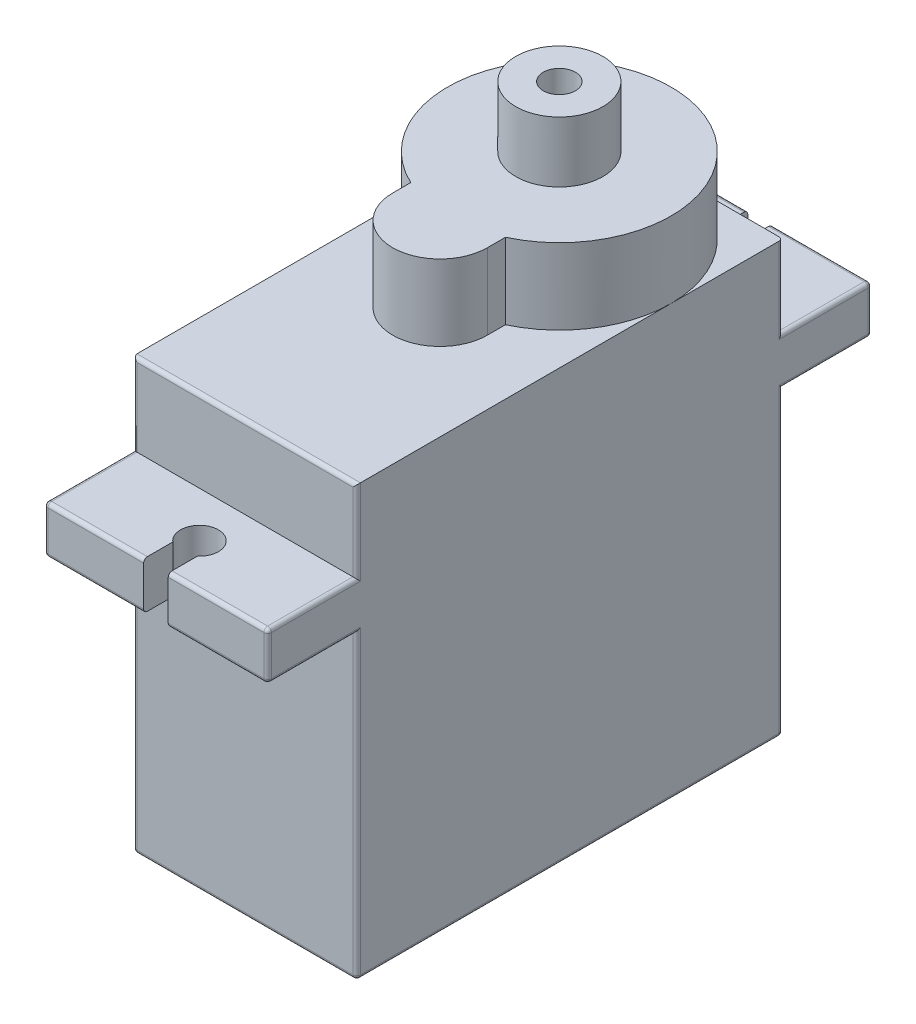
from build123d import *

# Parameters (mm, degrees)
ESQUISSE1_W        = 11.8
ESQUISSE1_H        = 22.5
BOSS_EXTRU_1_DEPTH = 15.9
BOSS_EXTRU_2_DEPTH = 2.5
ESQUISSE4_W        = 11.8
ESQUISSE4_H        = 22.5
BOSS_EXTRU_3_DEPTH = 4.3
BOSS_EXTRU_4_DEPTH = 4
ESQUISSE6_R        = 2.3
ESQUISSE6_R_2      = 0.85
BOSS_EXTRU_5_DEPTH = 3.2
CONG_1_R           = 0.2


with BuildPart() as part:
    # Esquisse1 → Boss.-Extru.1 (new body)
    with BuildSketch(Plane(origin=(0, 0, 0), x_dir=(1, 0, 0), z_dir=(0, 1, 0))):
        Rectangle(ESQUISSE1_W, ESQUISSE1_H)
    extrude(amount=BOSS_EXTRU_1_DEPTH)

    # Esquisse3 → Boss.-Extru.2 (add)
    with BuildSketch(Plane(origin=(0, 15.9, 0), x_dir=(1, 0, 0), z_dir=(0, 1, 0))):
        with BuildLine():
            Line((-5.9, 15.95), (-5.9, -15.95))
            Line((-5.9, -15.95), (-0.65, -15.95))
            Line((-0.65, -15.95), (-0.65, -14.409934208))
            ThreePointArc((-0.65, -14.409934208), (0, -12.65), (0.65, -14.409934208))
            Line((0.65, -14.409934208), (0.65, -15.95))
            Line((0.65, -15.95), (5.9, -15.95))
            Line((5.9, -15.95), (5.9, 15.95))
            Line((5.9, 15.95), (0.65, 15.95))
            Line((0.65, 15.95), (0.65, 14.409934208))
            ThreePointArc((0.65, 14.409934208), (0, 12.65), (-0.65, 14.409934208))
            Line((-0.65, 14.409934208), (-0.65, 15.95))
            Line((-0.65, 15.95), (-5.9, 15.95))
        make_face()
    extrude(amount=BOSS_EXTRU_2_DEPTH)

    # Esquisse4 → Boss.-Extru.3 (add)
    with BuildSketch(Plane(origin=(0, 18.4, 0), x_dir=(1, 0, 0), z_dir=(0, 1, 0))):
        Rectangle(ESQUISSE4_W, ESQUISSE4_H)
    extrude(amount=BOSS_EXTRU_3_DEPTH)

    # Esquisse5 → Boss.-Extru.4 (add)
    with BuildSketch(Plane(origin=(0, 22.7, 0), x_dir=(1, 0, 0), z_dir=(0, 1, 0))):
        with BuildLine():
            Line((2.5, -0.95), (2.5, 0.005844314))
            ThreePointArc((2.5, 0.005844314), (0, 11.25), (-2.5, 0.005844314))
            Line((-2.5, 0.005844314), (-2.5, -0.95))
            ThreePointArc((-2.5, -0.95), (0, -3.45), (2.5, -0.95))
        make_face()
    extrude(amount=BOSS_EXTRU_4_DEPTH)

    # Esquisse6 → Boss.-Extru.5 (add)
    with BuildSketch(Plane(origin=(0, 26.7, 0), x_dir=(1, 0, 0), z_dir=(0, 1, 0))):
        with Locations((0, 5.35)):
            Circle(ESQUISSE6_R)
        with Locations((0, 5.35)):
            Circle(ESQUISSE6_R_2, mode=Mode.SUBTRACT)
    extrude(amount=BOSS_EXTRU_5_DEPTH)

    # Congé1
    cong_1_edges = [part.edges().sort_by_distance(p)[0] for p in [
        (0, 0, -11.25),
        (-5.9, 17.15, -15.95),
        (5.9, 17.15, -15.95),
        (5.9, 15.9, -13.6),
        (5.9, 18.4, -13.6),
        (5.9, 20.55, -11.25),
        (-5.9, 20.55, -11.25),
        (3.275, 18.4, -15.95),
        (3.275, 15.9, -15.95),
        (-3.275, 18.4, -15.95),
        (-3.275, 15.9, -15.95),
        (-5.9, 15.9, -13.6),
        (-5.9, 18.4, -13.6),
        (5.9, 20.55, 11.25),
        (0, 22.7, 11.25),
        (-5.9, 20.55, 11.25),
        (5.9, 18.4, 13.6),
        (5.9, 15.9, 13.6),
        (5.9, 17.15, 15.95),
        (3.275, 18.4, 15.95),
        (3.275, 15.9, 15.95),
        (-5.9, 17.15, 15.95),
        (-3.275, 18.4, 15.95),
        (-3.275, 15.9, 15.95),
        (-5.9, 15.9, 13.6),
        (-5.9, 18.4, 13.6),
        (5.9, 7.95, -11.25),
        (5.9, 0, 0),
        (5.9, 7.95, 11.25),
        (0, 0, 11.25),
        (-5.9, 7.95, 11.25),
        (-5.9, 0, 0),
        (-5.9, 7.95, -11.25),
    ]]
    fillet(cong_1_edges, radius=CONG_1_R)


solid = part.part
